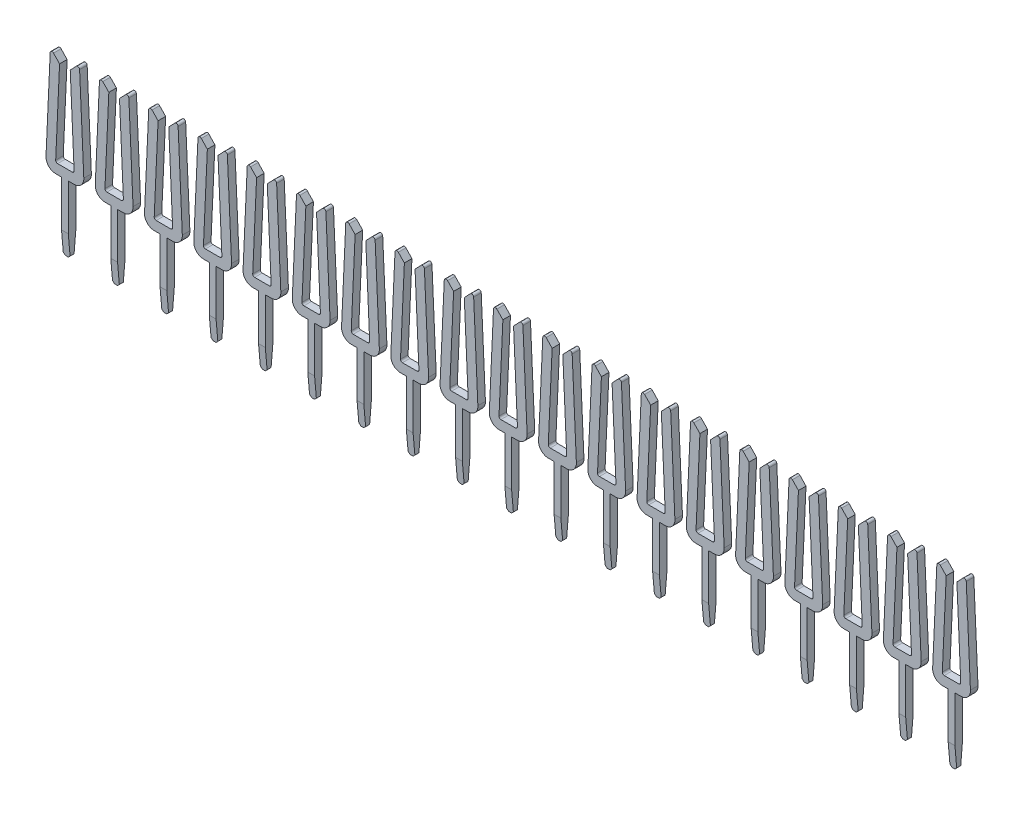
from build123d import *

# Parameters (mm, degrees)
EXTRUDE_688_DEPTH      = 0.195
CHAMFER_1_SIZE         = 0.1
CHAMFER_1_SIZE2        = 1.14300523
CHAMFER_2_SIZE         = 0.1
CHAMFER_2_SIZE2        = 1.14300523
PATTERN_LINEAR_1_COUNT = 19
PATTERN_LINEAR_1_PITCH = 2.54


with BuildPart() as part:
    # Sketch 215 → Extrude 688 (new, symmetric)
    with BuildSketch(Plane.XY):
        with BuildLine():
            Line((-0.275094226, 4.504536299), (-0.585991311, 4.829871514))
            ThreePointArc((-0.585991311, 4.829871514), (-0.693381247, 4.85442336), (-0.758184185, 4.765339295))
            Line((-0.758184185, 4.765339295), (-0.974480797, 0.022780107))
            ThreePointArc((-0.974480797, 0.022780107), (-0.836517671, -0.34540552), (-0.475, -0.5))
            Line((-0.475, -0.5), (-0.175, -0.5))
            Line((-0.175, -0.5), (-0.175, -3.9))
            Line((-0.175, -3.9), (-0.075, -4))
            Line((-0.075, -4), (0.075, -4))
            Line((0.075, -4), (0.175, -3.9))
            Line((0.175, -3.9), (0.175, -0.5))
            Line((0.175, -0.5), (0.475, -0.5))
            ThreePointArc((0.475, -0.5), (0.836517671, -0.34540552), (0.974480797, 0.022780107))
            Line((0.974480797, 0.022780107), (0.758184185, 4.765339295))
            ThreePointArc((0.758184185, 4.765339295), (0.693381247, 4.85442336), (0.585991311, 4.829871514))
            Line((0.585991311, 4.829871514), (0.275094226, 4.504536299))
            Line((0.275094226, 4.504536299), (0.474897057, 0.104536299))
            ThreePointArc((0.474897057, 0.104536299), (0.447296715, 0.030911759), (0.375, 0))
            Line((0.375, 0), (-0.375, 0))
            ThreePointArc((-0.375, 0), (-0.447296715, 0.030911759), (-0.474897057, 0.104536299))
            Line((-0.474897057, 0.104536299), (-0.275094226, 4.504536299))
        make_face()
    extrude(amount=EXTRUDE_688_DEPTH, both=True)

    # Фаска1
    chamfer_1_edges = [part.edges().sort_by_distance(p)[0] for p in [
        (0, -4, 0.195),
    ]]
    chamfer_1_side = [part.faces().sort_by_distance(p)[0] for p in [
        (0, -4, 0),
    ]]
    chamfer(chamfer_1_edges, length=CHAMFER_1_SIZE, length2=CHAMFER_1_SIZE2, reference=chamfer_1_side[0])

    # Фаска2
    chamfer_2_edges = [part.edges().sort_by_distance(p)[0] for p in [
        (0, -4, -0.195),
    ]]
    chamfer_2_side = [part.faces().sort_by_distance(p)[0] for p in [
        (0, -4, -0.05),
    ]]
    chamfer(chamfer_2_edges, length=CHAMFER_2_SIZE, length2=CHAMFER_2_SIZE2, reference=chamfer_2_side[0])


with BuildPart() as pattern_linear_1_1:
    # Линейный массив1: pattern copy
    add(part.part.moved(Location(Vector(-1, 0, 0) * (1 * PATTERN_LINEAR_1_PITCH))))


with BuildPart() as pattern_linear_1_2:
    # Линейный массив1: pattern copy
    add(part.part.moved(Location(Vector(-1, 0, 0) * (2 * PATTERN_LINEAR_1_PITCH))))


with BuildPart() as pattern_linear_1_3:
    # Линейный массив1: pattern copy
    add(part.part.moved(Location(Vector(-1, 0, 0) * (3 * PATTERN_LINEAR_1_PITCH))))


with BuildPart() as pattern_linear_1_4:
    # Линейный массив1: pattern copy
    add(part.part.moved(Location(Vector(-1, 0, 0) * (4 * PATTERN_LINEAR_1_PITCH))))


with BuildPart() as pattern_linear_1_5:
    # Линейный массив1: pattern copy
    add(part.part.moved(Location(Vector(-1, 0, 0) * (5 * PATTERN_LINEAR_1_PITCH))))


with BuildPart() as pattern_linear_1_6:
    # Линейный массив1: pattern copy
    add(part.part.moved(Location(Vector(-1, 0, 0) * (6 * PATTERN_LINEAR_1_PITCH))))


with BuildPart() as pattern_linear_1_7:
    # Линейный массив1: pattern copy
    add(part.part.moved(Location(Vector(-1, 0, 0) * (7 * PATTERN_LINEAR_1_PITCH))))


with BuildPart() as pattern_linear_1_8:
    # Линейный массив1: pattern copy
    add(part.part.moved(Location(Vector(-1, 0, 0) * (8 * PATTERN_LINEAR_1_PITCH))))


with BuildPart() as pattern_linear_1_9:
    # Линейный массив1: pattern copy
    add(part.part.moved(Location(Vector(-1, 0, 0) * (9 * PATTERN_LINEAR_1_PITCH))))


with BuildPart() as pattern_linear_1_10:
    # Линейный массив1: pattern copy
    add(part.part.moved(Location(Vector(-1, 0, 0) * (10 * PATTERN_LINEAR_1_PITCH))))


with BuildPart() as pattern_linear_1_11:
    # Линейный массив1: pattern copy
    add(part.part.moved(Location(Vector(-1, 0, 0) * (11 * PATTERN_LINEAR_1_PITCH))))


with BuildPart() as pattern_linear_1_12:
    # Линейный массив1: pattern copy
    add(part.part.moved(Location(Vector(-1, 0, 0) * (12 * PATTERN_LINEAR_1_PITCH))))


with BuildPart() as pattern_linear_1_13:
    # Линейный массив1: pattern copy
    add(part.part.moved(Location(Vector(-1, 0, 0) * (13 * PATTERN_LINEAR_1_PITCH))))


with BuildPart() as pattern_linear_1_14:
    # Линейный массив1: pattern copy
    add(part.part.moved(Location(Vector(-1, 0, 0) * (14 * PATTERN_LINEAR_1_PITCH))))


with BuildPart() as pattern_linear_1_15:
    # Линейный массив1: pattern copy
    add(part.part.moved(Location(Vector(-1, 0, 0) * (15 * PATTERN_LINEAR_1_PITCH))))


with BuildPart() as pattern_linear_1_16:
    # Линейный массив1: pattern copy
    add(part.part.moved(Location(Vector(-1, 0, 0) * (16 * PATTERN_LINEAR_1_PITCH))))


with BuildPart() as pattern_linear_1_17:
    # Линейный массив1: pattern copy
    add(part.part.moved(Location(Vector(-1, 0, 0) * (17 * PATTERN_LINEAR_1_PITCH))))


with BuildPart() as pattern_linear_1_18:
    # Линейный массив1: pattern copy
    add(part.part.moved(Location(Vector(-1, 0, 0) * (18 * PATTERN_LINEAR_1_PITCH))))


solid = Compound([part.part, pattern_linear_1_1.part, pattern_linear_1_2.part, pattern_linear_1_3.part, pattern_linear_1_4.part, pattern_linear_1_5.part, pattern_linear_1_6.part, pattern_linear_1_7.part, pattern_linear_1_8.part, pattern_linear_1_9.part, pattern_linear_1_10.part, pattern_linear_1_11.part, pattern_linear_1_12.part, pattern_linear_1_13.part, pattern_linear_1_14.part, pattern_linear_1_15.part, pattern_linear_1_16.part, pattern_linear_1_17.part, pattern_linear_1_18.part])
